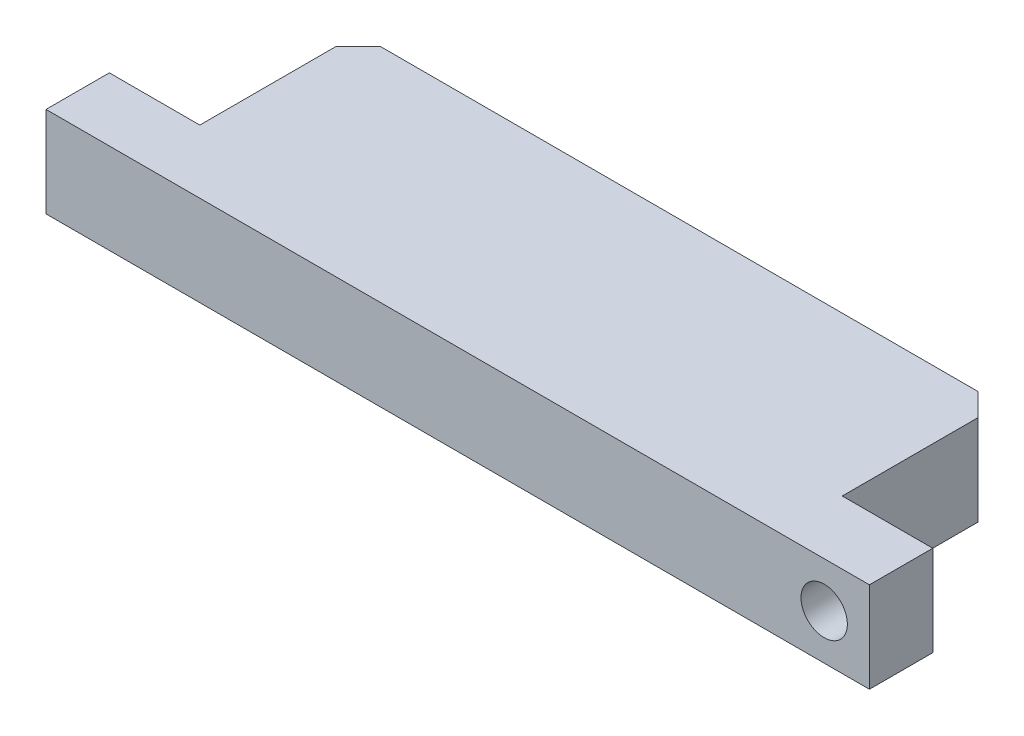
from build123d import *

# Parameters (mm, degrees)
SKETCH1_W                        = 36.4
SKETCH1_H                        = 9.8
BOSS_EXTRUDE1_DEPTH              = 4
SKETCH2_W                        = 4
SKETCH2_H                        = 6.999999999
CUT_EXTRUDE1_DEPTH               = 5
SKETCH3_W                        = 4
SKETCH3_H                        = 6.999999999
CUT_EXTRUDE2_DEPTH               = 5
F_2_05_2_05_DIAMETER_HOLE1_D     = 2.05
F_2_05_2_05_DIAMETER_HOLE1_DEPTH = 6.35
F_2_05_2_05_DIAMETER_HOLE1_TIP   = 0.615882135
F_2_05_2_05_DIAMETER_HOLE2_D     = 2.05
F_2_05_2_05_DIAMETER_HOLE2_DEPTH = 9.8
CHAMFER1_SIZE                    = 1


with BuildPart() as part:
    # Sketch1 → Boss-Extrude1 (new body)
    with BuildSketch(Plane(origin=(0, 4, 0), x_dir=(1, 0, 0), z_dir=(0, 1, 0))):
        with Locations((0, -4.9)):
            Rectangle(SKETCH1_W, SKETCH1_H)
    extrude(amount=-BOSS_EXTRUDE1_DEPTH)

    # Sketch2 → Cut-Extrude1 (cut, through all)
    with BuildSketch(Plane.XZ):
        with Locations((-16.2, 3.5)):
            Rectangle(SKETCH2_W, SKETCH2_H)
    extrude(amount=-CUT_EXTRUDE1_DEPTH, mode=Mode.SUBTRACT)

    # Sketch3 → Cut-Extrude2 (cut, through all)
    with BuildSketch(Plane.XZ):
        with Locations((16.2, 3.5)):
            Rectangle(SKETCH3_W, SKETCH3_H)
    extrude(amount=-CUT_EXTRUDE2_DEPTH, mode=Mode.SUBTRACT)

    # Ø2.05 (2.05) Diameter Hole1
    with Locations(Plane(origin=(0, 0, 0), x_dir=(-1, 0, 0), z_dir=(0, 0, -1))):
        with Locations((10, 2), (-10, 2)):
            Hole(F_2_05_2_05_DIAMETER_HOLE1_D / 2, depth=F_2_05_2_05_DIAMETER_HOLE1_DEPTH)
            with Locations((0, 0, -(F_2_05_2_05_DIAMETER_HOLE1_DEPTH + F_2_05_2_05_DIAMETER_HOLE1_TIP / 2))):  # 118° drill point
                Cone(0, F_2_05_2_05_DIAMETER_HOLE1_D / 2, F_2_05_2_05_DIAMETER_HOLE1_TIP, mode=Mode.SUBTRACT)

    # Ø2.05 (2.05) Diameter Hole2
    with Locations(Plane.XY.offset(9.8)):
        with Locations((16.2, 2)):
            Hole(F_2_05_2_05_DIAMETER_HOLE2_D / 2, depth=F_2_05_2_05_DIAMETER_HOLE2_DEPTH)

    # Chamfer1
    chamfer1_edges = [part.edges().sort_by_distance(p)[0] for p in [
        (-14.2, 2, 0),
        (14.2, 2, 0),
    ]]
    chamfer(chamfer1_edges, length=CHAMFER1_SIZE)


solid = part.part
